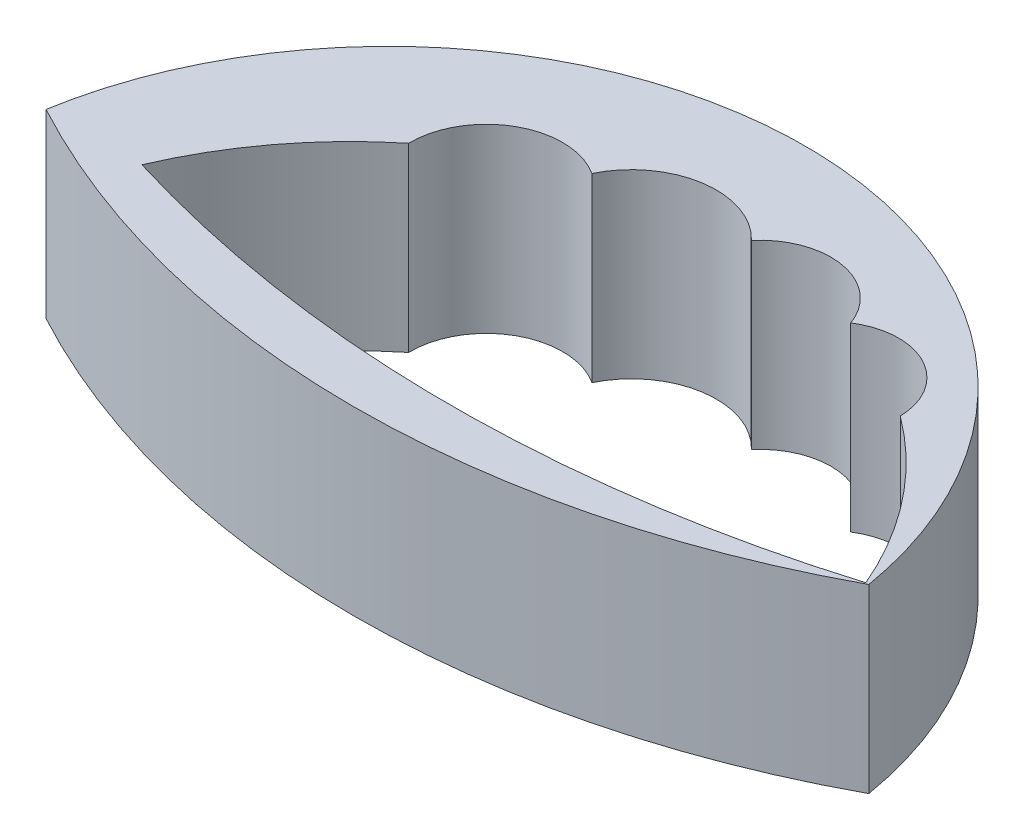
from build123d import *

# Parameters (mm, degrees)
BOSS_EXTRUDE1_DEPTH = 12.3
CUT_EXTRUDE1_DEPTH  = 13.3


with BuildPart() as part:
    # Sketch1 → Boss-Extrude1 (new body)
    with BuildSketch(Plane(origin=(0, 0, 0), x_dir=(1, 0, 0), z_dir=(0, 1, 0))):
        with BuildLine():
            ThreePointArc((0, 0), (27.937327101, 23.623695395), (55.874654202, 0))
            ThreePointArc((55.874654202, 0), (27.937327101, -7.03951799), (0, 0))
        make_face()
    extrude(amount=BOSS_EXTRUDE1_DEPTH)

    # Sketch2 → Cut-Extrude1 (cut, through all)
    with BuildSketch(Plane(origin=(0, 12.3, 0), x_dir=(1, 0, 0), z_dir=(0, 1, 0))):
        with BuildLine():
            ThreePointArc((6.512863529, 0), (9.77491486, 5.638211193), (14.304676712, 10.319200608))
            ThreePointArc((14.304676712, 10.319200608), (16.969047295, 14.945891186), (22.305064172, 14.766837577))
            ThreePointArc((22.305064172, 14.766837577), (26.593603486, 17.95377667), (31.656828978, 16.247348283))
            ThreePointArc((31.656828978, 16.247348283), (36.195985479, 17.887121813), (39.87791775, 14.766837577))
            ThreePointArc((39.87791775, 14.766837577), (44.568649172, 14.965090252), (47.03719079, 10.971524469))
            ThreePointArc((47.03719079, 10.971524469), (52.083128874, 6.059747982), (55.670118393, 0))
            ThreePointArc((55.670118393, 0), (31.091490961, -3.658407288), (6.512863529, 0))
        make_face()
    extrude(amount=-CUT_EXTRUDE1_DEPTH, mode=Mode.SUBTRACT)


solid = part.part
